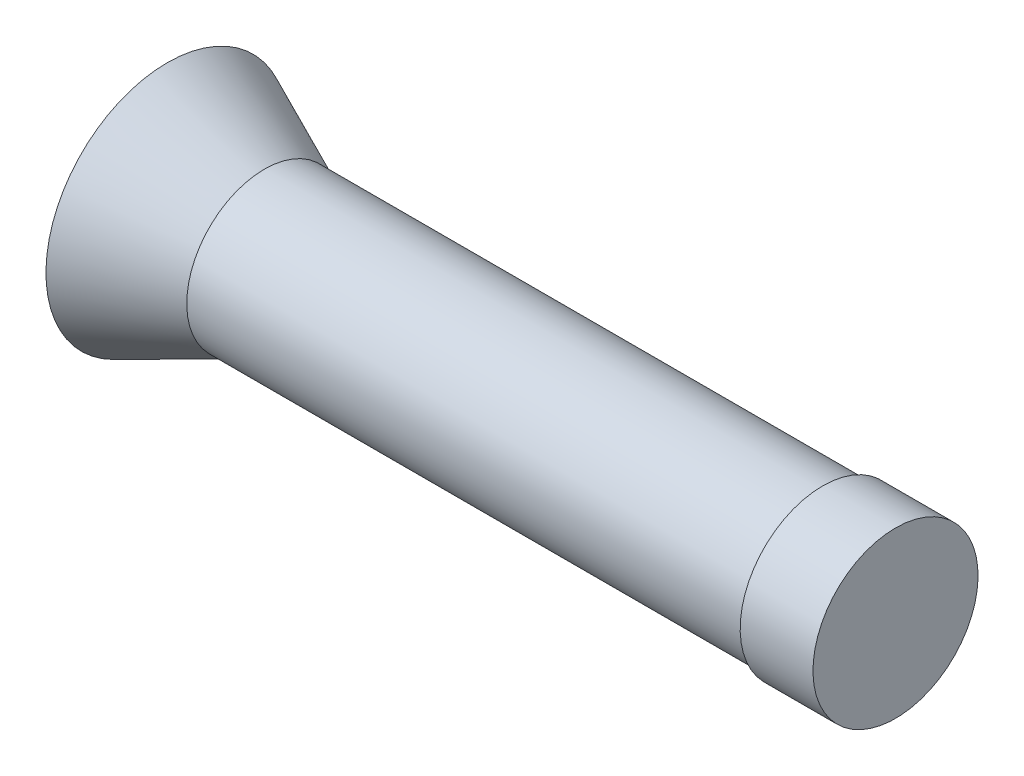
from build123d import *

# Parameters (mm, degrees)
SKETCH2_R          = 15
CUT_EXTRUDE1_DEPTH = 145


with BuildPart() as part:
    # Sketch1 → Revolve1 (revolve)
    with BuildSketch(Plane.XY):
        Polygon((-115, 0), (-135, 9), (-135, -16), (15, -16), (15, 1), (0, 1), (0, 0), align=None)
    revolve(axis=Axis((15, -16, 0), (-1, 0, 0)))

    # Sketch2 → Cut-Extrude1 (cut)
    with BuildSketch(Plane.ZY.offset(135)):
        with Locations((0, -16)):
            Circle(SKETCH2_R)
    extrude(amount=-CUT_EXTRUDE1_DEPTH, mode=Mode.SUBTRACT)


solid = part.part
